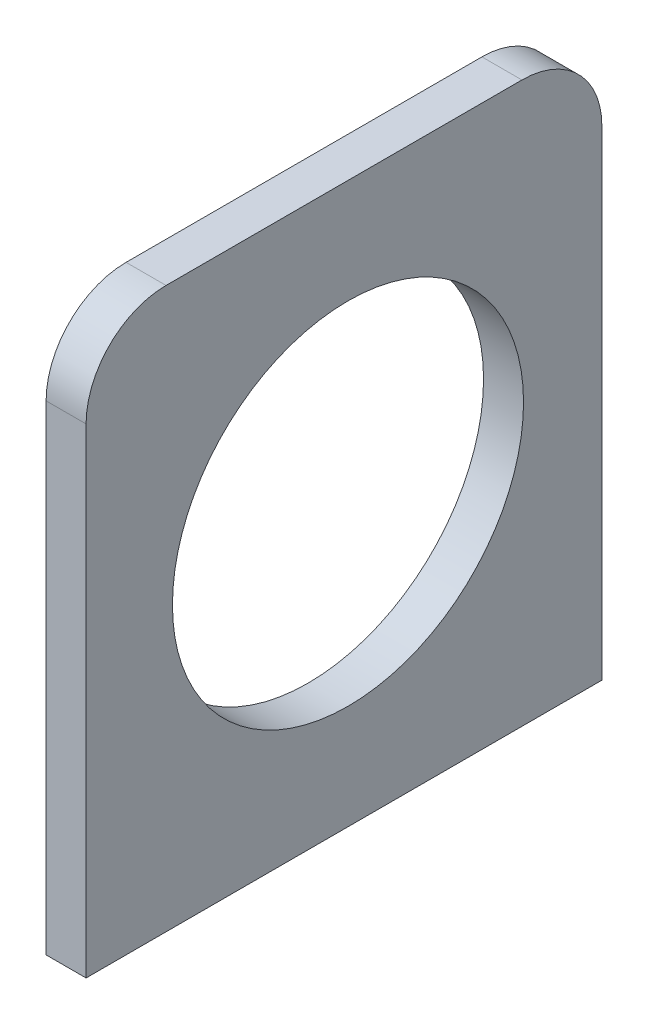
from build123d import *

# Parameters (mm, degrees)
SKETCH4_W           = 5
SKETCH4_H           = 70
BOSS_EXTRUDE1_DEPTH = 64.5
FILLET3_R           = 10
FILLET4_R           = 10
SKETCH5_R           = 21.9509271
CUT_EXTRUDE1_DEPTH  = 10


with BuildPart() as part:
    # Sketch4 → Boss-Extrude1 (new body)
    with BuildSketch(Plane.XY):
        with Locations((-0.263157895, -27.861842105)):
            Rectangle(SKETCH4_W, SKETCH4_H)
    extrude(amount=BOSS_EXTRUDE1_DEPTH)

    # Fillet3
    fillet3_edges = [part.edges().sort_by_distance(p)[0] for p in [
        (-0.263157895, 7.138157895, 64.5),
    ]]
    fillet(fillet3_edges, radius=FILLET3_R)

    # Fillet4
    fillet4_edges = [part.edges().sort_by_distance(p)[0] for p in [
        (-0.263157895, 7.138157895, 0),
    ]]
    fillet(fillet4_edges, radius=FILLET4_R)

    # Sketch5 → Cut-Extrude1 (cut)
    with BuildSketch(Plane.ZY.offset(2.763157895)):
        with Locations((31.75, -27.861842105)):
            Circle(SKETCH5_R)
    extrude(amount=-CUT_EXTRUDE1_DEPTH, mode=Mode.SUBTRACT)


solid = part.part
